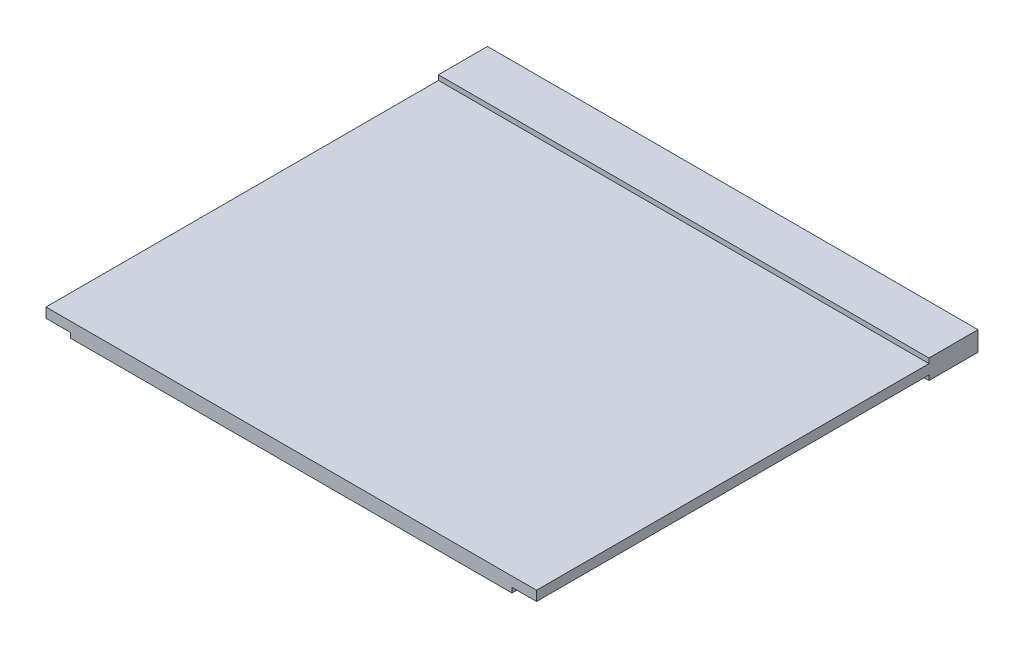
from build123d import *

# Parameters (mm, degrees)
SCHIZZO1_W                   = 50
SCHIZZO1_H                   = 2
ESTRUSIONE_ESTRUSIONE1_DEPTH = 5
SCHIZZO2_W                   = 50
SCHIZZO2_H                   = 1
ESTRUSIONE_ESTRUSIONE2_DEPTH = 40
SCHIZZO3_W                   = 45
SCHIZZO3_H                   = 1
ESTRUSIONE_ESTRUSIONE3_DEPTH = 0.5


with BuildPart() as part:
    # Schizzo1 → Estrusione-Estrusione1 (new body)
    with BuildSketch(Plane.XY):
        with Locations((15.607042649, 0.147727273)):
            Rectangle(SCHIZZO1_W, SCHIZZO1_H)
    extrude(amount=ESTRUSIONE_ESTRUSIONE1_DEPTH)

    # Schizzo2 → Estrusione-Estrusione2 (add)
    with BuildSketch(Plane.XY.offset(5)):
        with Locations((15.607042649, 0.147727273)):
            Rectangle(SCHIZZO2_W, SCHIZZO2_H)
    extrude(amount=ESTRUSIONE_ESTRUSIONE2_DEPTH)

    # Schizzo3 → Estrusione-Estrusione3 (add)
    with BuildSketch(Plane.XZ.offset(0.352272727)):
        with Locations((15.607042649, 44.5)):
            Rectangle(SCHIZZO3_W, SCHIZZO3_H)
        with Locations((15.607042649, 42)):
            Rectangle(SCHIZZO3_W, SCHIZZO3_H)
        with Locations((15.607042649, 39.5)):
            Rectangle(SCHIZZO3_W, SCHIZZO3_H)
        with Locations((15.607042649, 37)):
            Rectangle(SCHIZZO3_W, SCHIZZO3_H)
        with Locations((15.607042649, 34.5)):
            Rectangle(SCHIZZO3_W, SCHIZZO3_H)
        with Locations((15.607042649, 32)):
            Rectangle(SCHIZZO3_W, SCHIZZO3_H)
        with Locations((15.607042649, 29.5)):
            Rectangle(SCHIZZO3_W, SCHIZZO3_H)
        with Locations((15.607042649, 27)):
            Rectangle(SCHIZZO3_W, SCHIZZO3_H)
        with Locations((15.607042649, 24.5)):
            Rectangle(SCHIZZO3_W, SCHIZZO3_H)
        with Locations((15.607042649, 22)):
            Rectangle(SCHIZZO3_W, SCHIZZO3_H)
        with Locations((15.607042649, 19.5)):
            Rectangle(SCHIZZO3_W, SCHIZZO3_H)
        with Locations((15.607042649, 17)):
            Rectangle(SCHIZZO3_W, SCHIZZO3_H)
    extrude(amount=ESTRUSIONE_ESTRUSIONE3_DEPTH)


solid = part.part
